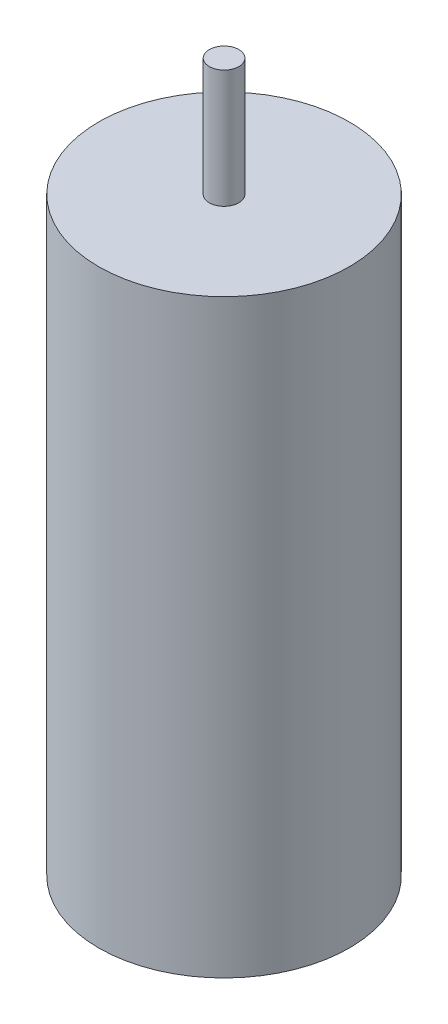
from build123d import *

# Parameters (mm, degrees)
SKETCH1_R           = 4.25
BOSS_EXTRUDE1_DEPTH = 20
SKETCH2_R           = 0.5
BOSS_EXTRUDE2_DEPTH = 4


with BuildPart() as part:
    # Sketch1 → Boss-Extrude1 (new body)
    with BuildSketch(Plane(origin=(0, 0, 0), x_dir=(1, 0, 0), z_dir=(0, 1, 0))):
        Circle(SKETCH1_R)
    extrude(amount=BOSS_EXTRUDE1_DEPTH)

    # Sketch2 → Boss-Extrude2 (add)
    with BuildSketch(Plane(origin=(0, 20, 0), x_dir=(1, 0, 0), z_dir=(0, 1, 0))):
        Circle(SKETCH2_R)
    extrude(amount=BOSS_EXTRUDE2_DEPTH)


solid = part.part
